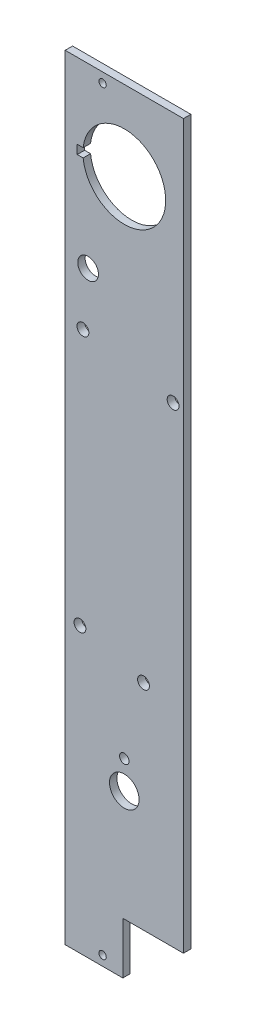
from build123d import *

# Parameters (mm, degrees)
SKETCH1_W           = 40
SKETCH1_H           = 262
SKETCH1_R           = 1.25
BOSS_EXTRUDE1_DEPTH = 2.5
SKETCH2_R           = 5
SKETCH2_R_2         = 1.6
SKETCH2_R_3         = 2
SKETCH2_R_4         = 3.5
CUT_EXTRUDE1_DEPTH  = 3.5
SKETCH3_W           = 20.5
SKETCH3_H           = 17.5
CUT_EXTRUDE2_DEPTH  = 3.5


with BuildPart() as part:
    # Sketch1 → Boss-Extrude1 (new body)
    with BuildSketch(Plane.XY):
        with Locations((20, 131)):
            Rectangle(SKETCH1_W, SKETCH1_H)
        with Locations((12.65, 258.7)):
            Circle(SKETCH1_R, mode=Mode.SUBTRACT)
        with Locations((12.65, 3.3)):
            Circle(SKETCH1_R, mode=Mode.SUBTRACT)
    extrude(amount=BOSS_EXTRUDE1_DEPTH)

    # Sketch2 → Cut-Extrude1 (cut, through all)
    with BuildSketch(Plane.XY.offset(2.5)):
        with Locations((20, 55.004773675)):
            Circle(SKETCH2_R)
        with Locations((20, 64.504773675)):
            Circle(SKETCH2_R_2)
        with Locations((5, 96)):
            Circle(SKETCH2_R_3)
        with Locations((26.5, 90)):
            Circle(SKETCH2_R_3)
        with Locations((36.5, 177)):
            Circle(SKETCH2_R_3)
        with Locations((6, 183.25)):
            Circle(SKETCH2_R_3)
        with Locations((7.75, 202)):
            Circle(SKETCH2_R_4)
        with BuildLine():
            Line((6.080589093, 233.49778539), (4.080589089, 233.49778539))
            Line((4.080589089, 233.49778539), (4.080589089, 236.49778539))
            Line((4.080589089, 236.49778539), (6.080589093, 236.49778539))
            ThreePointArc((6.080589093, 236.49778539), (34, 234.99778539), (6.080589093, 233.49778539))
        make_face()
    extrude(amount=-CUT_EXTRUDE1_DEPTH, mode=Mode.SUBTRACT)

    # Sketch3 → Cut-Extrude2 (cut, through all)
    with BuildSketch(Plane.XY.offset(2.5)):
        with Locations((29.75, 8.75)):
            Rectangle(SKETCH3_W, SKETCH3_H)
    extrude(amount=-CUT_EXTRUDE2_DEPTH, mode=Mode.SUBTRACT)


solid = part.part
